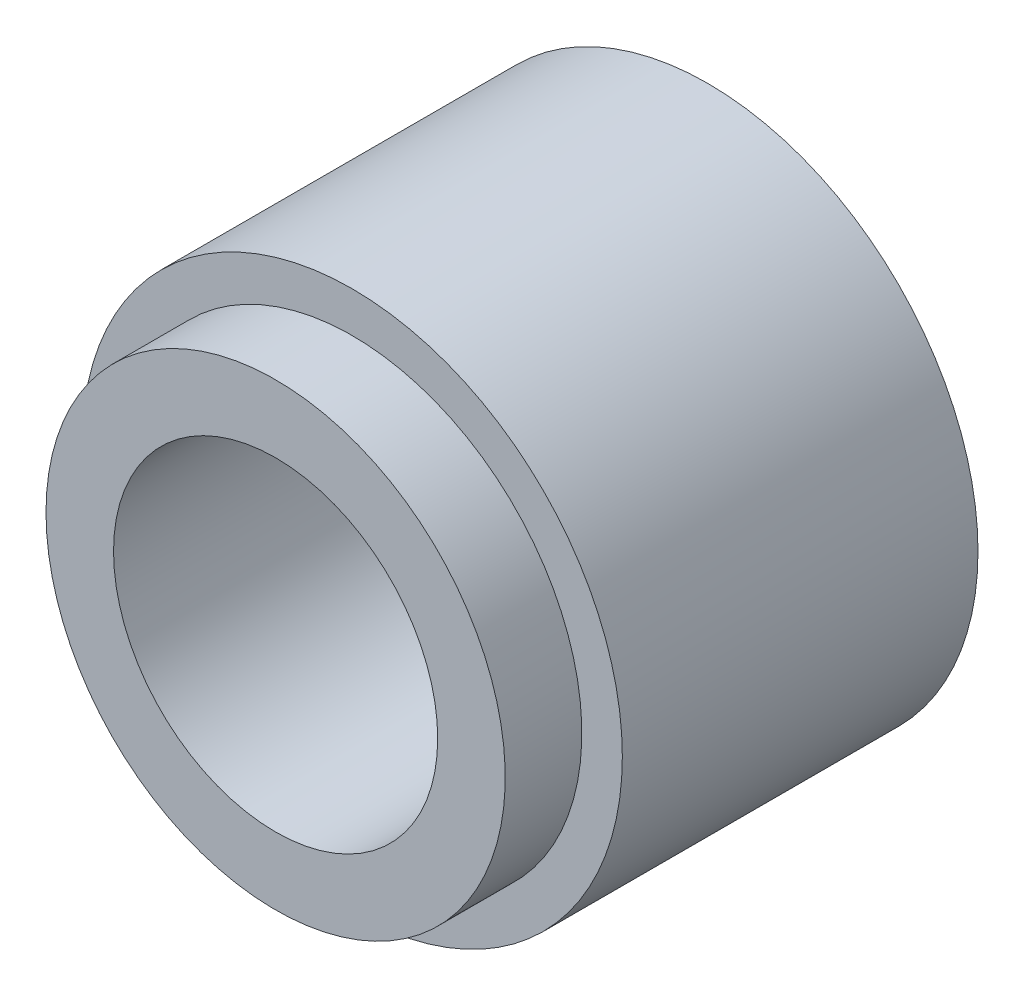
from build123d import *


with BuildPart() as part:
    # Sketch1 → Revolve1 (revolve)
    with BuildSketch(Plane(origin=(0, 0, 0), x_dir=(0, 0, -1), z_dir=(1, 0, 0))):
        Polygon((-25.4, 26.9875), (-16.4, 26.9875), (-16.4, 31.75), (25.4, 31.75), (25.4, 19.05), (-25.4, 19.05), align=None)
    revolve(axis=Axis((0, 0, -25.4), (0, 0, 1)))


solid = part.part
